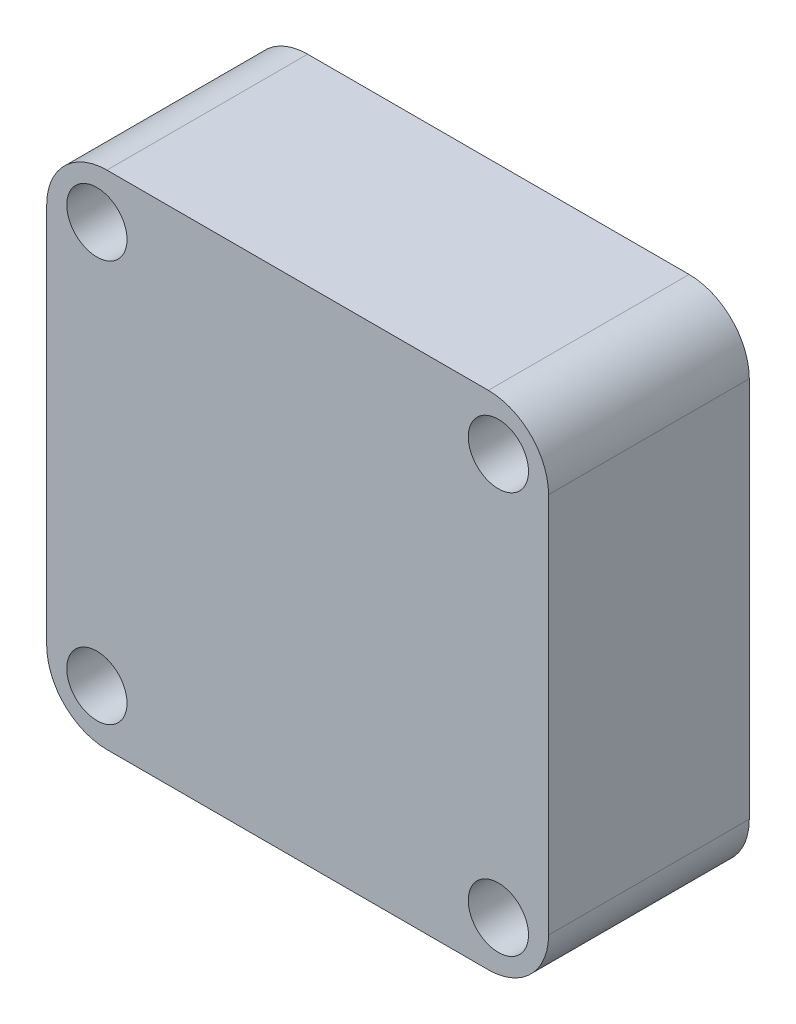
from build123d import *

# Parameters (mm, degrees)
SKETCH1_R           = 1.5
BOSS_EXTRUDE1_DEPTH = 10


with BuildPart() as part:
    # Sketch1 → Boss-Extrude1 (new body)
    with BuildSketch(Plane.XY):
        with BuildLine():
            Line((-9.5, -107.5), (9.5, -107.5))
            ThreePointArc((9.5, -107.5), (11.621320344, -108.378679656), (12.5, -110.5))
            Line((12.5, -110.5), (12.5, -129.5))
            ThreePointArc((12.5, -129.5), (11.621320344, -131.621320344), (9.5, -132.5))
            Line((9.5, -132.5), (-9.5, -132.5))
            ThreePointArc((-9.5, -132.5), (-11.621320344, -131.621320344), (-12.5, -129.5))
            Line((-12.5, -129.5), (-12.5, -110.5))
            ThreePointArc((-12.5, -110.5), (-11.621320344, -108.378679656), (-9.5, -107.5))
        make_face()
        with Locations((10, -130)):
            Circle(SKETCH1_R, mode=Mode.SUBTRACT)
        with Locations((10, -110)):
            Circle(SKETCH1_R, mode=Mode.SUBTRACT)
        with Locations((-10, -110)):
            Circle(SKETCH1_R, mode=Mode.SUBTRACT)
        with Locations((-10, -130)):
            Circle(SKETCH1_R, mode=Mode.SUBTRACT)
    extrude(amount=-BOSS_EXTRUDE1_DEPTH)


solid = part.part
